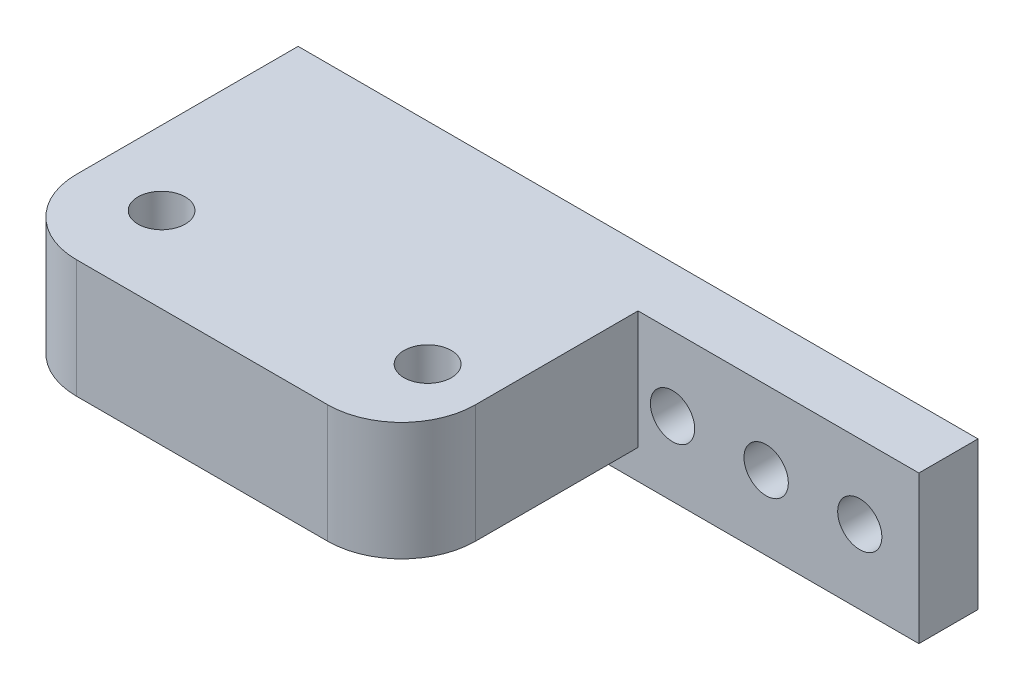
from build123d import *

# Parameters (mm, degrees)
SKETCH1_W           = 46
SKETCH1_H           = 10
BOSS_EXTRUDE1_DEPTH = 4
SKETCH4_W           = 27
SKETCH4_H           = 8
BOSS_EXTRUDE2_DEPTH = 16
SKETCH5_R           = 1.600993429
SKETCH5_R_2         = 1.598160281
CUT_EXTRUDE2_DEPTH  = 16
SKETCH6_R           = 1.494820838
SKETCH6_R_2         = 1.5
CUT_EXTRUDE3_DEPTH  = 16
FILLET1_R           = 5


with BuildPart() as part:
    # Sketch1 → Boss-Extrude1 (new body)
    with BuildSketch(Plane.XY):
        with Locations((23, 5)):
            Rectangle(SKETCH1_W, SKETCH1_H)
    extrude(amount=BOSS_EXTRUDE1_DEPTH)

    # Sketch4 → Boss-Extrude2 (add)
    with BuildSketch(Plane.XY.offset(4)):
        with Locations((13.5, 6)):
            Rectangle(SKETCH4_W, SKETCH4_H)
    extrude(amount=BOSS_EXTRUDE2_DEPTH)

    # Sketch5 → Cut-Extrude2 (cut)
    with BuildSketch(Plane.XZ.offset(-2)):
        with Locations((22.999560123, 14.235930167)):
            Circle(SKETCH5_R)
        with Locations((5.001441553, 14.237615424)):
            Circle(SKETCH5_R_2)
    extrude(amount=-CUT_EXTRUDE2_DEPTH, mode=Mode.SUBTRACT)

    # Sketch6 → Cut-Extrude3 (cut)
    with BuildSketch(Plane(origin=(0, 0, 0), x_dir=(-1, 0, 0), z_dir=(0, 0, -1))):
        with Locations((-42, 5)):
            Circle(SKETCH6_R)
        with Locations((-29.333333333, 5)):
            Circle(SKETCH6_R_2)
        with Locations((-35.666666667, 5)):
            Circle(SKETCH6_R_2)
    extrude(amount=-CUT_EXTRUDE3_DEPTH, mode=Mode.SUBTRACT)

    # Fillet1
    fillet1_edges = [part.edges().sort_by_distance(p)[0] for p in [
        (0, 6, 20),
        (27, 6, 20),
    ]]
    fillet(fillet1_edges, radius=FILLET1_R)


solid = part.part
